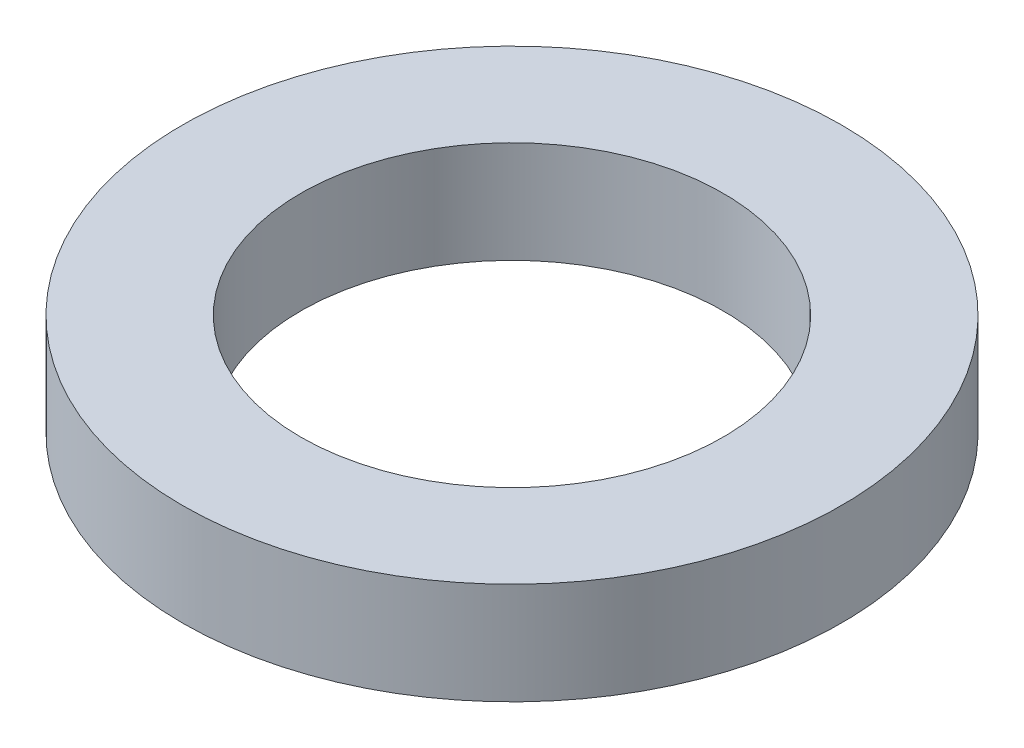
from build123d import *

# Parameters (mm, degrees)
SKETCH_1_R      = 11
SKETCH_1_R_2    = 7.05
EXTRUDE_1_DEPTH = 3.4


with BuildPart() as part:
    # 草图1 → 凸台-拉伸1 (new body)
    with BuildSketch(Plane(origin=(0, 0, 0), x_dir=(1, 0, 0), z_dir=(0, 1, 0))):
        Circle(SKETCH_1_R)
        Circle(SKETCH_1_R_2, mode=Mode.SUBTRACT)
    extrude(amount=EXTRUDE_1_DEPTH)


solid = part.part
